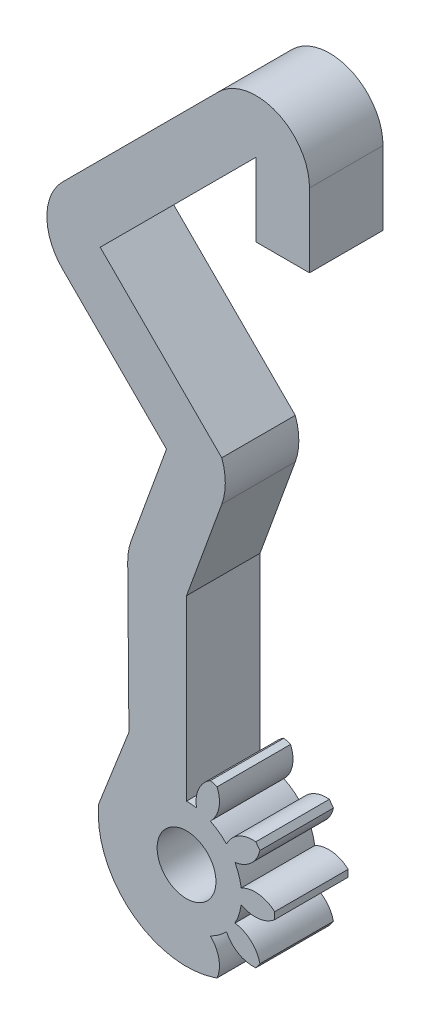
from build123d import *

# Parameters (mm, degrees)
BOSS_EXTRUDE1_DEPTH = 5
BOSS_EXTRUDE2_DEPTH = 5
CUT_EXTRUDE1_REACH  = 7
SKETCH3_R           = 2


with BuildPart() as part:
    # Sketch1 → Boss-Extrude1 (new body)
    with BuildSketch(Plane.XY):
        with BuildLine():
            Line((-2.520114714, 12.117440709), (-2.520114714, 6.269831909))
            Line((-2.520114714, 6.269831909), (-0.666012747, 0.563492811))
            ThreePointArc((-0.666012747, 0.563492811), (-6.290753591, 1.602682623), (-8.48865141, 6.883484665))
            Line((-8.48865141, 6.883484665), (-6.437898745, 12.117778688))
            Line((-6.437898745, 12.117778688), (-6.520114714, 22.117440709))
            ThreePointArc((-6.520114714, 22.117440709), (-6.459345726, 22.81203342), (-6.278885197, 23.485521282))
            Line((-6.278885197, 23.485521282), (-3.883018647, 30.068110528))
            Line((-3.883018647, 30.068110528), (-10.954086459, 37.13917834))
            ThreePointArc((-10.954086459, 37.13917834), (-12.015892078, 39.702603869), (-10.954086459, 42.266029397))
            Line((-10.954086459, 42.266029397), (-0.347484741, 52.872631115))
            ThreePointArc((-0.347484741, 52.872631115), (3.603256686, 53.658482445), (5.841171936, 50.309205586))
            Line((5.841171936, 50.309205586), (5.841171936, 45.309205586))
            Line((5.841171936, 45.309205586), (2.215940787, 45.309205586))
            Line((2.215940787, 45.309205586), (2.215940787, 50.309205586))
            Line((2.215940787, 50.309205586), (-8.39066093, 39.702603869))
            Line((-8.39066093, 39.702603869), (-0.124248164, 31.436191102))
            ThreePointArc((-0.124248164, 31.436191102), (0.116981353, 30.068110528), (-0.124248164, 28.700029955))
            Line((-0.124248164, 28.700029955), (-2.520114714, 22.117440709))
            Line((-2.520114714, 22.117440709), (-2.520114714, 12.117440709))
        make_face()
    extrude(amount=BOSS_EXTRUDE1_DEPTH)

    # Sketch2 → Boss-Extrude2 (add)
    with BuildSketch(Plane.XY.offset(5)):
        with BuildLine():
            Line((-0.666012747, 0.563492811), (-0.444155406, 0.640409829))
            ThreePointArc((-0.444155406, 0.640409829), (-0.320137366, 1.836179716), (-0.904060997, 2.887026655))
            ThreePointArc((-0.904060997, 2.887026655), (-0.316507803, 3.236827197), (0.197736204, 3.687529179))
            ThreePointArc((0.197736204, 3.687529179), (1.016708708, 2.807455242), (2.192277133, 2.55589019))
            Line((2.192277133, 2.55589019), (2.468262924, 2.935752043))
            ThreePointArc((2.468262924, 2.935752043), (1.865739721, 3.976046178), (0.775663247, 4.482977511))
            ThreePointArc((0.775663247, 4.482977511), (1.045396166, 5.111327197), (1.196512329, 5.778217803))
            ThreePointArc((1.196512329, 5.778217803), (2.376369483, 5.547602991), (3.475290544, 6.035064372))
            Line((3.475290544, 6.035064372), (3.475290544, 6.504599445))
            ThreePointArc((3.475290544, 6.504599445), (2.376369483, 6.992060826), (1.196512329, 6.761446014))
            ThreePointArc((1.196512329, 6.761446014), (1.045396166, 7.428336621), (0.775663247, 8.056686306))
            ThreePointArc((0.775663247, 8.056686306), (1.865739721, 8.56361764), (2.468262924, 9.603911774))
            Line((2.468262924, 9.603911774), (2.192277133, 9.983773627))
            ThreePointArc((2.192277133, 9.983773627), (1.016708708, 9.732208576), (0.197736204, 8.852134639))
            ThreePointArc((0.197736204, 8.852134639), (-0.316507803, 9.302836621), (-0.904060997, 9.652637162))
            ThreePointArc((-0.904060997, 9.652637162), (-0.320137366, 10.703484102), (-0.444155406, 11.899253988))
            Line((-0.444155406, 11.899253988), (-0.890709796, 12.044348305))
            ThreePointArc((-0.890709796, 12.044348305), (-1.693898402, 11.14984612), (-1.839166595, 9.956471389))
            ThreePointArc((-1.839166595, 9.956471389), (-2.178215907, 10.003209228), (-2.520114714, 10.018831909))
            Line((-2.520114714, 10.018831909), (-2.520114714, 8.269831909))
            ThreePointArc((-2.520114714, 8.269831909), (-0.544738032, 6.582700839), (-1.902080725, 4.367718876))
            Line((-1.902080725, 4.367718876), (-0.666012747, 0.563492811))
        make_face()
    extrude(amount=-BOSS_EXTRUDE2_DEPTH)

    # Sketch3 → Cut-Extrude1 (cut, up to next)
    with BuildSketch(Plane.XY.offset(5), mode=Mode.PRIVATE) as cut_extrude1_sk1:
        with Locations((-2.520114714, 6.269831909)):
            Circle(SKETCH3_R)
    cut_extrude1_tool1 = extrude(cut_extrude1_sk1.sketch, amount=-CUT_EXTRUDE1_REACH, mode=Mode.PRIVATE) & part.part
    add(cut_extrude1_tool1.solids().sort_by_distance((-2.520115, 6.269832, 5))[0], mode=Mode.SUBTRACT)


solid = part.part
